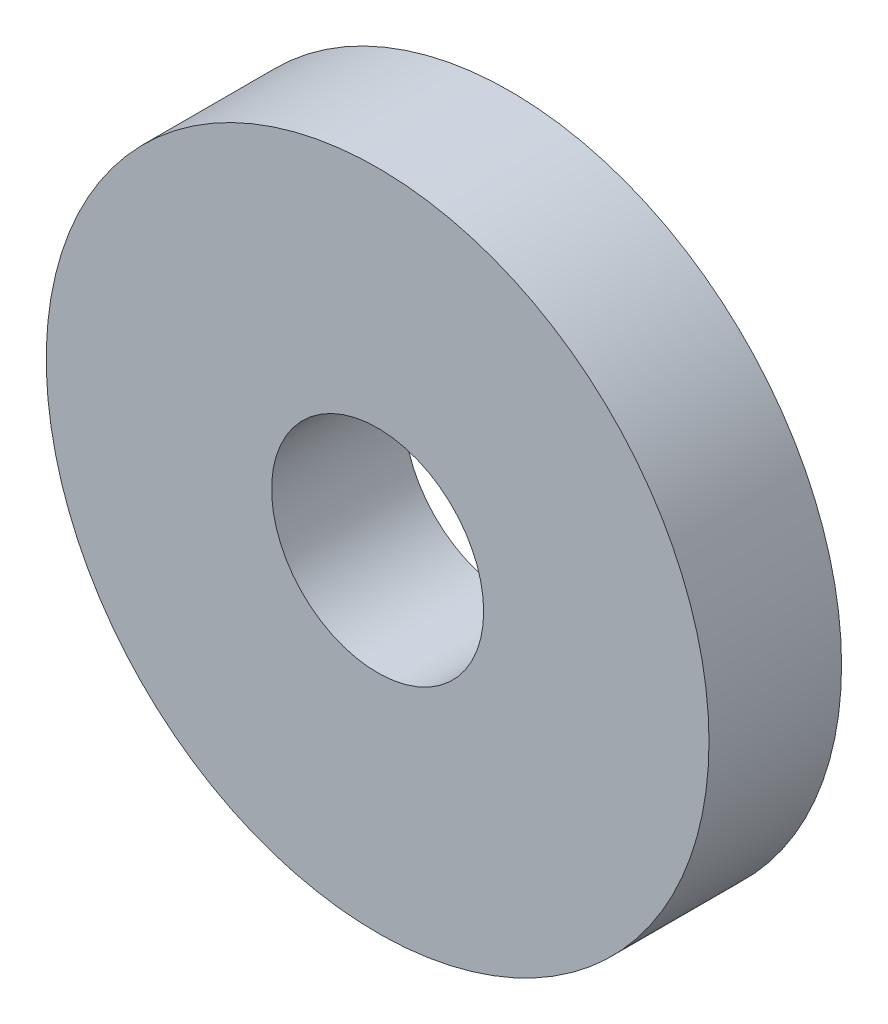
from build123d import *

# Parameters (mm, degrees)
SKETCH1_R           = 12.5
SKETCH1_R_2         = 4
BOSS_EXTRUDE1_DEPTH = 5


with BuildPart() as part:
    # Sketch1 → Boss-Extrude1 (new body)
    with BuildSketch(Plane.XY):
        Circle(SKETCH1_R)
        Circle(SKETCH1_R_2, mode=Mode.SUBTRACT)
    extrude(amount=BOSS_EXTRUDE1_DEPTH)


solid = part.part
